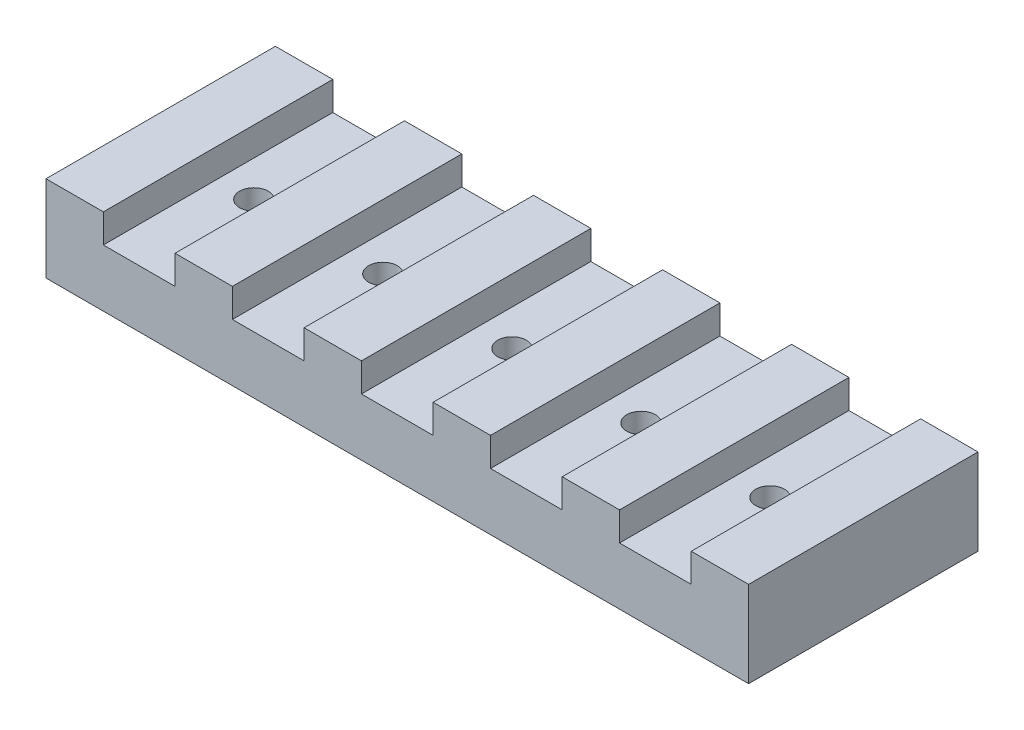
from build123d import *

# Parameters (mm, degrees)
SKETCH1_W           = 155.575
SKETCH1_H           = 12.7
SKETCH1_W_2         = 12.7
SKETCH1_H_2         = 6.35
BOSS_EXTRUDE1_DEPTH = 25.4
SKETCH2_R           = 3.175
CUT_EXTRUDE1_DEPTH  = 13.7


with BuildPart() as part:
    # Sketch1 → Boss-Extrude1 (new body, symmetric)
    with BuildSketch(Plane.XY):
        Rectangle(SKETCH1_W, SKETCH1_H)
        with Locations((71.4375, 9.525)):
            Rectangle(SKETCH1_W_2, SKETCH1_H_2)
        with Locations((42.8625, 9.525)):
            Rectangle(SKETCH1_W_2, SKETCH1_H_2)
        with Locations((14.2875, 9.525)):
            Rectangle(SKETCH1_W_2, SKETCH1_H_2)
        with Locations((-14.2875, 9.525)):
            Rectangle(SKETCH1_W_2, SKETCH1_H_2)
        with Locations((-71.4375, 9.525)):
            Rectangle(SKETCH1_W_2, SKETCH1_H_2)
        with Locations((-42.8625, 9.525)):
            Rectangle(SKETCH1_W_2, SKETCH1_H_2)
    extrude(amount=BOSS_EXTRUDE1_DEPTH, both=True)

    # Sketch2 → Cut-Extrude1 (cut, through all)
    with BuildSketch(Plane(origin=(0, 6.35, 0), x_dir=(1, 0, 0), z_dir=(0, 1, 0))):
        Circle(SKETCH2_R)
        with Locations((-28.575, 0)):
            Circle(SKETCH2_R)
        with Locations((-57.15, 0)):
            Circle(SKETCH2_R)
    cut_extrude1 = extrude(amount=-CUT_EXTRUDE1_DEPTH, mode=Mode.SUBTRACT)

    # Mirror1: Cut-Extrude1 across plane
    add(cut_extrude1.mirror(Plane(origin=(0, 0, 0), x_dir=(0, 0, 1), z_dir=(1, 0, 0))), mode=Mode.SUBTRACT)


solid = part.part
